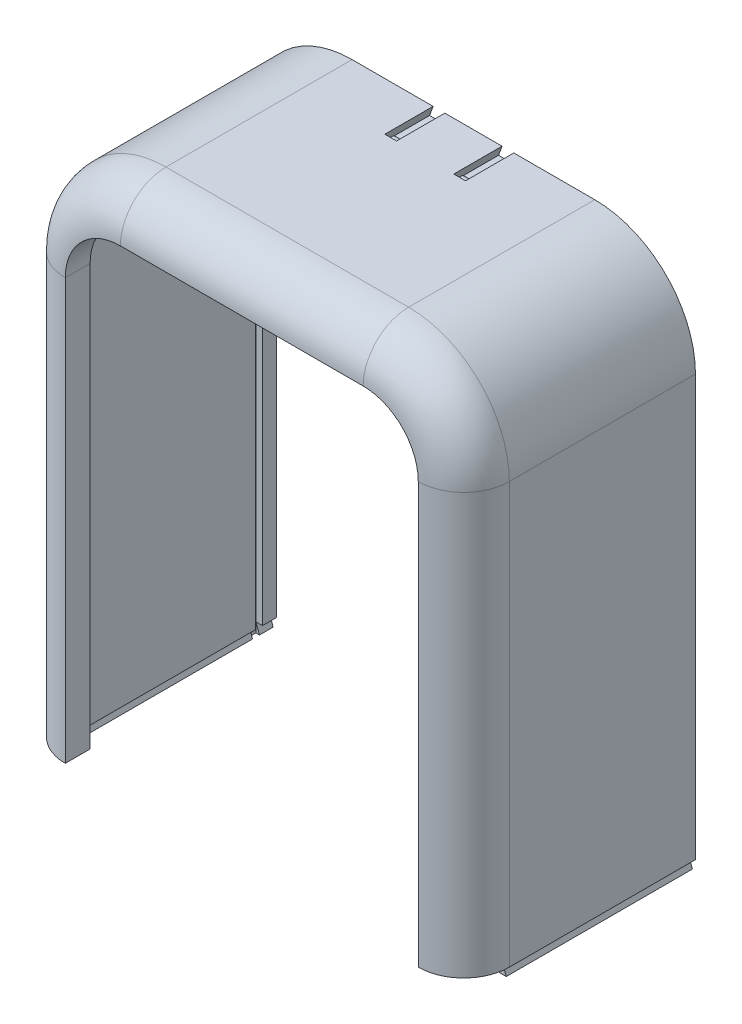
from build123d import *

# Parameters (mm, degrees)
EXTRUDE_1_DEPTH     = 27
CUT_EXTRUDE_1_DEPTH = 1
CUT_EXTRUDE_4_DEPTH = 7
EXTRUDE_2_DEPTH     = 6.5


with BuildPart() as part:
    # 草圖1 → 填料-伸長1 (new body)
    with BuildSketch(Plane.XY):
        with BuildLine():
            Line((-32.2, 25), (-32.2, -36))
            Line((-32.2, -36), (-31.25, -36))
            Line((-31.25, -36), (-31.759558328, -37.4))
            Line((-31.759558328, -37.4), (-29.040441672, -37.4))
            Line((-29.040441672, -37.4), (-29.55, -36))
            Line((-29.55, -36), (-28.6, -36))
            Line((-28.6, -36), (-28.6, 25))
            ThreePointArc((-28.6, 25), (-25.378174593, 32.778174593), (-17.6, 36))
            Line((-17.6, 36), (17.6, 36))
            ThreePointArc((17.6, 36), (25.378174593, 32.778174593), (28.6, 25))
            Line((28.6, 25), (28.6, -36))
            Line((28.6, -36), (29.55, -36))
            Line((29.55, -36), (29.040441672, -37.4))
            Line((29.040441672, -37.4), (31.759558328, -37.4))
            Line((31.759558328, -37.4), (31.25, -36))
            Line((31.25, -36), (32.2, -36))
            Line((32.2, -36), (32.2, 25))
            ThreePointArc((32.2, 25), (27.923759005, 35.323759005), (17.6, 39.6))
            Line((17.6, 39.6), (-17.6, 39.6))
            ThreePointArc((-17.6, 39.6), (-27.923759005, 35.323759005), (-32.2, 25))
        make_face()
    extrude(amount=EXTRUDE_1_DEPTH)

    # 草圖4 → 除料-伸長1 (cut)
    with BuildSketch(Plane.XY.offset(3)):
        with BuildLine():
            Line((-28.6, -36), (-28.6, 25))
            ThreePointArc((-28.6, 25), (-25.378174593, 32.778174593), (-17.6, 36))
            Line((-17.6, 36), (17.6, 36))
            ThreePointArc((17.6, 36), (25.378174593, 32.778174593), (28.6, 25))
            Line((28.6, 25), (28.6, -36))
            Line((28.6, -36), (28.6, -37.4))
            Line((28.6, -37.4), (29.56, -37.4))
            Line((29.56, -37.4), (29.56, -36))
            Line((29.56, -36), (29.56, 25))
            ThreePointArc((29.56, 25), (26.056997103, 33.456997103), (17.6, 36.96))
            Line((17.6, 36.96), (-17.6, 36.96))
            ThreePointArc((-17.6, 36.96), (-26.056997103, 33.456997103), (-29.56, 25))
            Line((-29.56, 25), (-29.56, -36))
            Line((-29.56, -36), (-29.56, -37.4))
            Line((-29.56, -37.4), (-28.6, -37.4))
            Line((-28.6, -37.4), (-28.6, -36))
        make_face()
    extrude(amount=-CUT_EXTRUDE_1_DEPTH, mode=Mode.SUBTRACT)

    # 掃出2: sweep along a path in 草圖5
    with BuildLine(Plane.XY.offset(27)) as sweep_2_path:
        Line((-30.4, -36), (-30.4, 25))
        ThreePointArc((-30.4, 25), (-26.650966799, 34.050966799), (-17.6, 37.8))
        Line((-17.6, 37.8), (17.6, 37.8))
        ThreePointArc((17.6, 37.8), (26.650966799, 34.050966799), (30.4, 25))
        Line((30.4, 25), (30.4, -36))
    # 草圖7 → 掃出2 (sweep)
    with BuildSketch(Plane.XZ.offset(36)):
        with BuildLine():
            Line((-28.6, 27), (-32.2, 27))
            ThreePointArc((-32.2, 27), (-30.266904756, 31.666904756), (-25.6, 33.6))
            Line((-25.6, 33.6), (-25.6, 30))
            ThreePointArc((-25.6, 30), (-27.721320344, 29.121320344), (-28.6, 27))
        make_face()
    sweep(path=sweep_2_path.line)

    # 草圖9 → 除料-伸長4 (cut)
    with BuildSketch(Plane(origin=(0, 0, 0), x_dir=(-1, 0, 0), z_dir=(0, 0, -1))):
        Polygon((-5.85, 39.6), (-6.359558328, 38.2), (-3.640441672, 38.2), (-4.15, 39.6), align=None)
        Polygon((5.85, 39.6), (4.15, 39.6), (3.640441672, 38.2), (6.359558328, 38.2), align=None)
    extrude(amount=-CUT_EXTRUDE_4_DEPTH, mode=Mode.SUBTRACT)

    # 草圖10 → 填料-伸長2 (add, symmetric)
    with BuildSketch(Plane(origin=(0, 0, 0), x_dir=(0, 0, -1), z_dir=(1, 0, 0))):
        with BuildLine():
            Line((-5.9, 38.2), (-5.1, 38.2))
            ThreePointArc((-5.1, 38.2), (-5.5, 38.334643123), (-5.9, 38.2))
        make_face()
    extrude(amount=EXTRUDE_2_DEPTH, both=True)


solid = part.part
